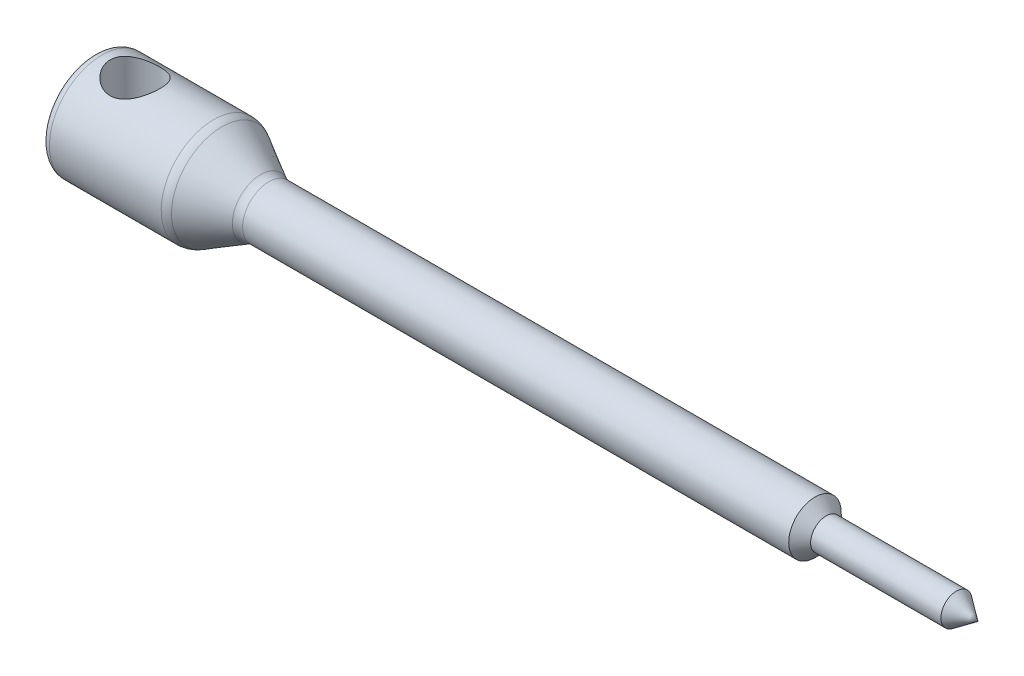
from build123d import *

# Parameters (mm, degrees)
CUT_EXTRUDE1_DEPTH      = 10
CUT_EXTRUDE1_DEPTH_BACK = 10
SKETCH2_R               = 3
FILLET1_R               = 1
FILLET2_R               = 2
SKETCH3_R               = 1.5
CUT_EXTRUDE2_DEPTH      = 6


with BuildPart() as part:
    # Sketch1 → Revolve1 (revolve)
    with BuildSketch(Plane.XY):
        Polygon((0, 0), (0, 6.325), (15, 6.325), (20.6, 3.165), (86.95, 3.165), (88.3, 1.875), (104, 1.875), (106.6, 0), align=None)
    revolve(axis=Axis((106.6, 0, 0), (-1, 0, 0)))

    # Sketch2 → Cut-Extrude1 (cut, two sides: drawn at the far end of the back side and taken through both)
    with BuildSketch(Plane(origin=(0, 0, 0), x_dir=(1, 0, 0), z_dir=(0, 1, 0)).offset(-CUT_EXTRUDE1_DEPTH_BACK)):
        with Locations((5, 0)):
            Circle(SKETCH2_R)
    extrude(amount=CUT_EXTRUDE1_DEPTH + CUT_EXTRUDE1_DEPTH_BACK, mode=Mode.SUBTRACT)

    # Fillet1
    fillet1_edges = [part.edges().sort_by_distance(p)[0] for p in [
        (0, -6.325, 0),
    ]]
    fillet(fillet1_edges, radius=FILLET1_R)

    # Fillet2
    fillet2_edges = [part.edges().sort_by_distance(p)[0] for p in [
        (20.6, -3.165, 0),
        (15, -6.325, 0),
    ]]
    fillet(fillet2_edges, radius=FILLET2_R)

    # Sketch3 → Cut-Extrude2 (cut)
    with BuildSketch(Plane.ZY):
        Circle(SKETCH3_R)
    extrude(amount=-CUT_EXTRUDE2_DEPTH, mode=Mode.SUBTRACT)


solid = part.part
